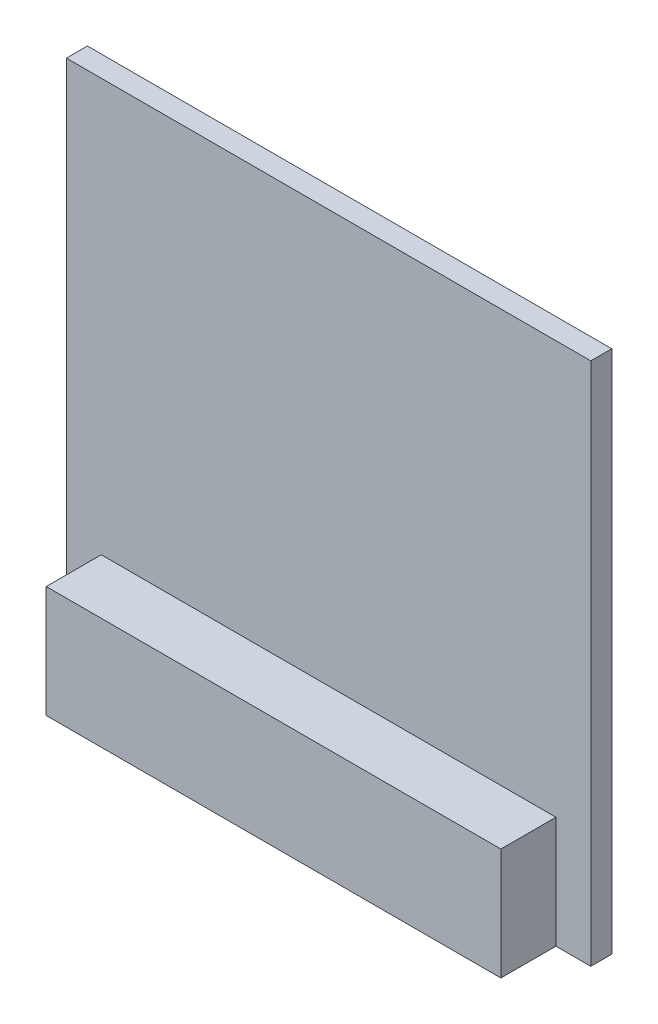
from build123d import *

# Parameters (mm, degrees)
SKETCH1_W           = 25.4
SKETCH1_H           = 25.4
BOSS_EXTRUDE1_DEPTH = 1.016
SKETCH2_W           = 22.0218
SKETCH2_H           = 5.4102
BOSS_EXTRUDE2_DEPTH = 2.667
SKETCH3_W           = 8.0264
SKETCH3_H           = 7.9756
BOSS_EXTRUDE3_DEPTH = 3.58902


with BuildPart() as part:
    # Sketch1 → Boss-Extrude1 (new body)
    with BuildSketch(Plane.XY):
        Rectangle(SKETCH1_W, SKETCH1_H)
    extrude(amount=BOSS_EXTRUDE1_DEPTH)

    # Sketch2 → Boss-Extrude2 (add)
    with BuildSketch(Plane.XY.offset(1.016)):
        with Locations((0, -9.9949)):
            Rectangle(SKETCH2_W, SKETCH2_H)
    extrude(amount=BOSS_EXTRUDE2_DEPTH)

    # Sketch3 → Boss-Extrude3 (add)
    with BuildSketch(Plane(origin=(0, 0, 0), x_dir=(-1, 0, 0), z_dir=(0, 0, -1))):
        with Locations((0, -3.4798)):
            Rectangle(SKETCH3_W, SKETCH3_H)
    extrude(amount=BOSS_EXTRUDE3_DEPTH)


solid = part.part
